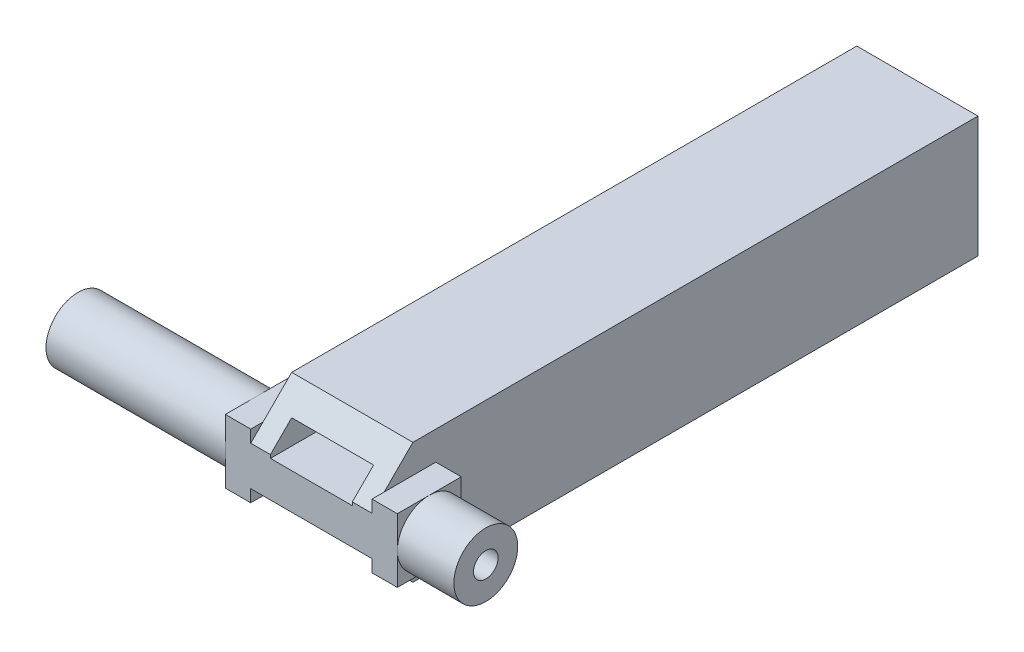
from build123d import *

# Parameters (mm, degrees)
SKETCH_1_W          = 74
SKETCH_1_H          = 14.8
EXTRUDE_1_DEPTH     = 14.8
SKETCH_2_W          = 10
SKETCH_2_H          = 10
CUT_EXTRUDE_1_DEPTH = 65
SKETCH_3_R          = 3.9
EXTRUDE_2_DEPTH     = 10
SKETCH_4_R          = 3.9
EXTRUDE_3_DEPTH     = 25
CHAMFER_1_SIZE      = 5
CUT_EXTRUDE_2_DEPTH = 6
SKETCH_8_R          = 1.5
CUT_EXTRUDE_4_DEPTH = 50.8
SKETCH_9_W          = 7.8
SKETCH_9_H          = 7.8
SKETCH_9_R          = 1.5
EXTRUDE_4_DEPTH     = 3.1
SKETCH_10_W         = 7.8
SKETCH_10_H         = 7.8
EXTRUDE_5_DEPTH     = 3.1
SKETCH_11_W         = 10
SKETCH_11_H         = 3
CUT_EXTRUDE_5_DEPTH = 10


with BuildPart() as part:
    # Эскиз1 → Бобышка-Вытянуть1 (new body)
    with BuildSketch(Plane(origin=(0, 0, 0), x_dir=(0, 0, -1), z_dir=(1, 0, 0))):
        Rectangle(SKETCH_1_W, SKETCH_1_H)
    extrude(amount=EXTRUDE_1_DEPTH)

    # Эскиз2 → Вырез-Вытянуть1 (cut)
    with BuildSketch(Plane(origin=(0, 0, -37), x_dir=(-1, 0, 0), z_dir=(0, 0, -1))):
        with Locations((-7.4, 0)):
            Rectangle(SKETCH_2_W, SKETCH_2_H)
    extrude(amount=-CUT_EXTRUDE_1_DEPTH, mode=Mode.SUBTRACT)

    # Эскиз3 → Бобышка-Вытянуть2 (add)
    with BuildSketch(Plane(origin=(14.8, 0, 0), x_dir=(0, 0, -1), z_dir=(1, 0, 0))):
        with Locations(Location((-33.1, 0, 0), (0, 0, 180))):  # turned: the seam where the file's is
            Circle(SKETCH_3_R)
    extrude(amount=EXTRUDE_2_DEPTH)

    # Эскиз4 → Бобышка-Вытянуть3 (add)
    with BuildSketch(Plane.ZY):
        with Locations((33.1, 0)):
            Circle(SKETCH_4_R)
    extrude(amount=EXTRUDE_3_DEPTH)

    # Фаска1
    chamfer_1_edges = [part.edges().sort_by_distance(p)[0] for p in [
        (7.4, 7.4, 37),
        (7.4, -7.4, 37),
    ]]
    chamfer(chamfer_1_edges, length=CHAMFER_1_SIZE)

    # Эскиз5 → Вырез-Вытянуть2 (cut)
    with BuildSketch(Plane.ZY.offset(25)):
        Polygon((30.011815854, 2.11733764), (33.920911448, 3.653232048), (36.188184146, -2.11733764), (32.279088552, -3.653232048), align=None)
    extrude(amount=-CUT_EXTRUDE_2_DEPTH, mode=Mode.SUBTRACT)

    # Эскиз8 → Вырез-Вытянуть4 (cut, through all)
    with BuildSketch(Plane(origin=(24.8, 0, 0), x_dir=(0, 0, -1), z_dir=(1, 0, 0))):
        with Locations((-33.1, 0)):
            Circle(SKETCH_8_R)
    extrude(amount=-CUT_EXTRUDE_4_DEPTH, mode=Mode.SUBTRACT)

    # Эскиз9 → Бобышка-Вытянуть4 (add)
    with BuildSketch(Plane.ZY):
        with Locations((33.1, 0)):
            Rectangle(SKETCH_9_W, SKETCH_9_H)
        with Locations(Location((33.1, 0, 0), (0, 0, 180))):  # turned: the seam where the file's is
            Circle(SKETCH_9_R, mode=Mode.SUBTRACT)
    extrude(amount=EXTRUDE_4_DEPTH)

    # Эскиз10 → Бобышка-Вытянуть5 (add)
    with BuildSketch(Plane(origin=(14.8, 0, 0), x_dir=(0, 0, -1), z_dir=(1, 0, 0))):
        with Locations((-33.1, 0)):
            Rectangle(SKETCH_10_W, SKETCH_10_H)
    extrude(amount=EXTRUDE_5_DEPTH)

    # Эскиз11 → Вырез-Вытянуть5 (cut, through all)
    with BuildSketch(Plane(origin=(0, 0, 28), x_dir=(-1, 0, 0), z_dir=(0, 0, -1))):
        with Locations((-7.4, 3.5)):
            Rectangle(SKETCH_11_W, SKETCH_11_H)
    extrude(amount=-CUT_EXTRUDE_5_DEPTH, mode=Mode.SUBTRACT)


solid = part.part
